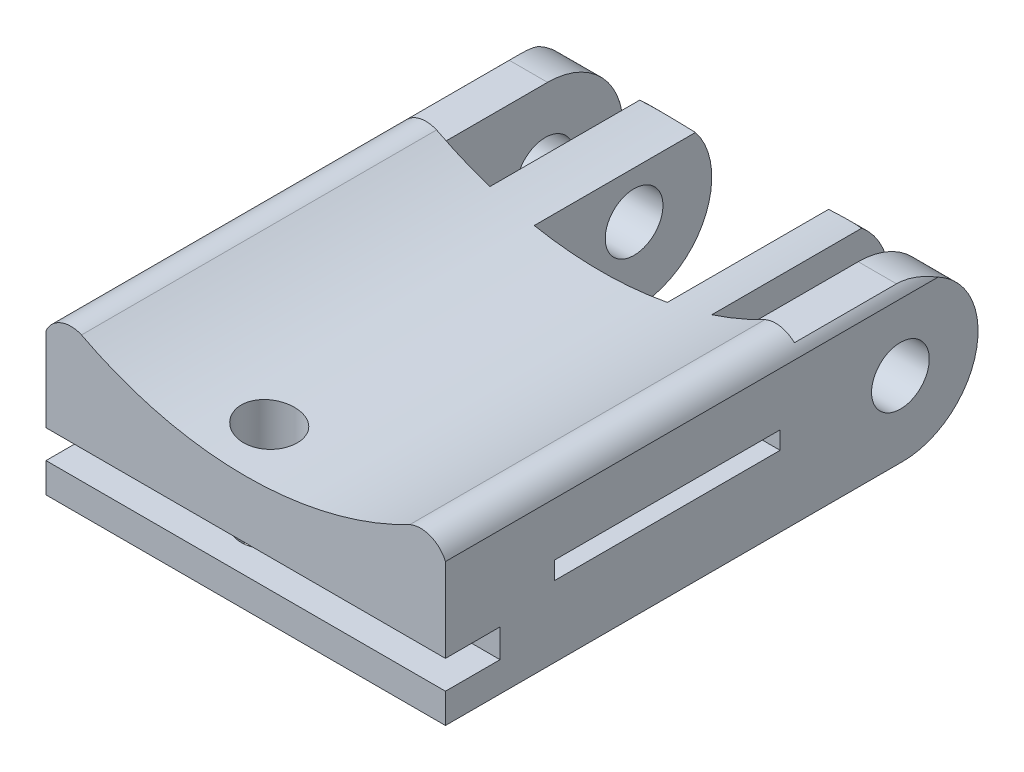
from build123d import *

# Parameters (mm, degrees)
BOSS_EXTRUDE1_DEPTH = 20
CUT_EXTRUDE19_DEPTH = 45
CUT_EXTRUDE23_DEPTH = 444
SKETCH10_W          = 25.4
SKETCH10_H          = 2
CUT_EXTRUDE25_DEPTH = 45
CUT_EXTRUDE26_DEPTH = 444
SKETCH16_R          = 3.25
SKETCH16_R_2        = 3.15
CUT_EXTRUDE28_DEPTH = 45
SKETCH18_R          = 3.15
CUT_EXTRUDE30_DEPTH = 20
CUT_EXTRUDE31_DEPTH = 6.15


with BuildPart() as part:
    # Sketch1 → Boss-Extrude1 (new body)
    with BuildSketch(Plane(origin=(0, 0, 0), x_dir=(1, 0, 0), z_dir=(0, 1, 0))):
        Polygon((-22.5, -50), (22.5, -50), (22.5, 10), (17.5, 10), (17.5, -10), (12.5, -10), (12.5, 10), (7.5, 10), (7.5, -10), (2.5, -10), (-2.5, -10), (-7.5, -10), (-7.5, 10), (-12.5, 10), (-12.5, -10), (-17.5, -10), (-17.5, 10), (-22.5, 10), align=None)
    extrude(amount=BOSS_EXTRUDE1_DEPTH)

    # Sketch6 → Cut-Extrude19 (cut)
    with BuildSketch(Plane(origin=(22.5, 0, 0), x_dir=(0, 0, -1), z_dir=(1, 0, 0))):
        with BuildLine():
            ThreePointArc((10, 8.5), (7.51040764, 2.48959236), (1.5, 0))
            Line((1.5, 0), (10, 0))
            Line((10, 0), (10, 8.5))
        make_face()
        with BuildLine():
            ThreePointArc((1.5, 17), (7.51040764, 14.51040764), (10, 8.5))
            Line((10, 8.5), (10, 20))
            Line((10, 20), (-10, 20))
            Line((-10, 20), (-10, 17))
            Line((-10, 17), (1.5, 17))
        make_face()
    extrude(amount=-CUT_EXTRUDE19_DEPTH, mode=Mode.SUBTRACT)

    # Sketch2 → Cut-Extrude23 (cut)
    with BuildSketch(Plane.XY.offset(50)):
        with BuildLine():
            Line((-22.5, 20), (22.5, 20))
            Line((22.5, 20), (22.5, 16))
            ThreePointArc((22.5, 16), (20.832845478, 17.631987193), (18.5, 17.607120136))
            ThreePointArc((18.5, 17.607120136), (0, 13.071891388), (-18.5, 17.607120136))
            ThreePointArc((-18.5, 17.607120136), (-20.832845478, 17.631987193), (-22.5, 16))
            Line((-22.5, 16), (-22.5, 20))
        make_face()
    extrude(amount=-CUT_EXTRUDE23_DEPTH, mode=Mode.SUBTRACT)

    # Sketch10 → Cut-Extrude25 (cut)
    with BuildSketch(Plane.ZY.offset(22.5)):
        Polygon((37.7, 10), (37.7, 8), (12.3, 8), (12.3, 10), (25, 10), align=None)
        with Locations((-25, 9)):
            Rectangle(SKETCH10_W, SKETCH10_H)
        Polygon((-303.835718962, 8), (-292.208543952, 8), (-279.508543952, 8), (-279.508543952, 10), (-292.208543952, 10), (-303.835718962, 10), align=None)
        Polygon((-329.508543952, 10), (-329.508543952, 8), (-354.908543952, 8), (-354.908543952, 10), (-342.208543952, 10), align=None)
        Polygon((-229.508543952, 8), (-254.908543952, 8), (-254.908543952, 10), (-242.208543952, 10), (-229.508543952, 10), align=None)
    extrude(amount=-CUT_EXTRUDE25_DEPTH, mode=Mode.SUBTRACT)

    # Sketch12 → Cut-Extrude26 (cut)
    with BuildSketch(Plane.XY.offset(50)):
        Polygon((-1, 3.35), (-1, 6.55), (0, 6.55), (1, 6.55), (1, 3.35), align=None)
    extrude(amount=-CUT_EXTRUDE26_DEPTH, mode=Mode.SUBTRACT)

    # Sketch16 → Cut-Extrude28 (cut)
    with BuildSketch(Plane.ZY.offset(22.5)):
        with Locations((-1.25, 8.5)):
            Circle(SKETCH16_R)
        with Locations((-386.058543952, 2.588831384)):
            Circle(SKETCH16_R_2)
    extrude(amount=-CUT_EXTRUDE28_DEPTH, mode=Mode.SUBTRACT)

    # Sketch18 → Cut-Extrude30 (cut)
    with BuildSketch(Plane.XZ):
        with Locations((-3.5, 43.85)):
            Circle(SKETCH18_R)
    extrude(amount=-CUT_EXTRUDE30_DEPTH, mode=Mode.SUBTRACT)

    # Sketch24 → Cut-Extrude31 (cut)
    with BuildSketch(Plane.XY.offset(50)):
        Polygon((-1, 6.55), (-11, 6.55), (-22.5, 6.55), (-22.5, 3.35), (-11, 3.35), (-1, 3.35), (1, 3.35), (11, 3.35), (22.5, 3.35), (22.5, 6.55), (11, 6.55), (1, 6.55), align=None)
    extrude(amount=-CUT_EXTRUDE31_DEPTH, mode=Mode.SUBTRACT)


solid = part.part
